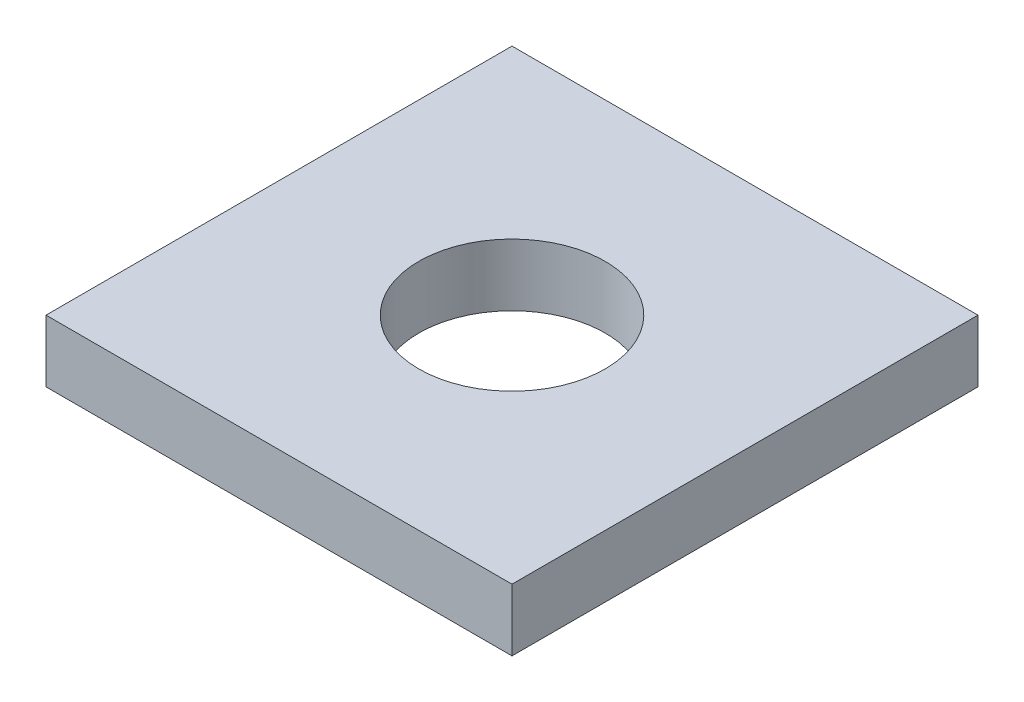
from build123d import *

# Parameters (mm, degrees)
SKETCH1_W           = 7.62
SKETCH1_H           = 7.62
SKETCH1_R           = 1.524
BOSS_EXTRUDE1_DEPTH = 1.016


with BuildPart() as part:
    # Sketch1 → Boss-Extrude1 (new body)
    with BuildSketch(Plane(origin=(0, 0, 0), x_dir=(1, 0, 0), z_dir=(0, 1, 0))):
        Rectangle(SKETCH1_W, SKETCH1_H)
        Circle(SKETCH1_R, mode=Mode.SUBTRACT)
    extrude(amount=BOSS_EXTRUDE1_DEPTH)


solid = part.part
